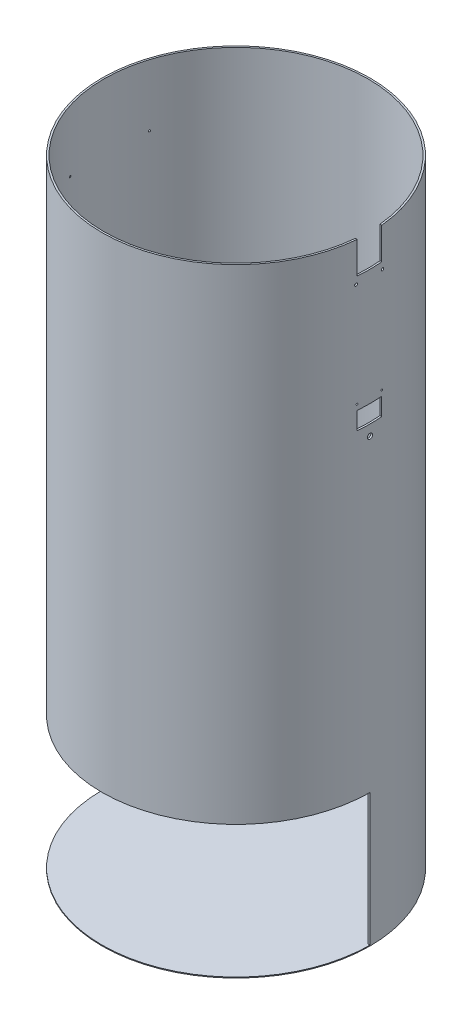
from build123d import *

# Parameters (mm, degrees)
ESQUISSE1_R             = 152
ESQUISSE1_R_2           = 150
BOSS_EXTRU_1_DEPTH      = 700
ESQUISSE2_R             = 152
BOSS_EXTRU_2_DEPTH      = 1
ESQUISSE6_W             = 304
ESQUISSE6_H             = 150
ENL_V_MAT_EXTRU_3_DEPTH = 152
ESQUISSE7_R             = 1.5
ENL_V_MAT_EXTRU_4_DEPTH = 240
ESQUISSE8_R             = 3
ESQUISSE8_R_2           = 1
ESQUISSE8_W             = 28
ESQUISSE8_H             = 20
ENL_V_MAT_EXTRU_5_DEPTH = 220
ESQUISSE9_R             = 1
ENL_V_MAT_EXTRU_6_DEPTH = 170
ESQUISSE10_R            = 1
ENL_V_MAT_EXTRU_8_DEPTH = 220


with BuildPart() as part:
    # Esquisse1 → Boss.-Extru.1 (new body)
    with BuildSketch(Plane(origin=(0, 0, 0), x_dir=(1, 0, 0), z_dir=(0, 1, 0))):
        with Locations(Location((0, 0, 0), (0, 0, 270))):
            Circle(ESQUISSE1_R)
        with Locations(Location((0, 0, 0), (0, 0, 270))):
            Circle(ESQUISSE1_R_2, mode=Mode.SUBTRACT)
    extrude(amount=-BOSS_EXTRU_1_DEPTH)

    # Esquisse2 → Boss.-Extru.2 (add)
    with BuildSketch(Plane(origin=(0, -700, 0), x_dir=(-1, 0, 0), z_dir=(0, -1, 0))):
        with Locations(Location((0, 0, 0), (0, 0, 270))):
            Circle(ESQUISSE2_R)
    extrude(amount=BOSS_EXTRU_2_DEPTH)

    # Esquisse6 → Enlèv. mat.-Extru.3 (cut)
    with BuildSketch(Plane.XY):
        with Locations((0, -625)):
            Rectangle(ESQUISSE6_W, ESQUISSE6_H)
    extrude(amount=ENL_V_MAT_EXTRU_3_DEPTH, mode=Mode.SUBTRACT)

    # Esquisse7 → Enlèv. mat.-Extru.4 (cut)
    with BuildSketch(Plane(origin=(0, 0, 0), x_dir=(0, 0, -1), z_dir=(1, 0, 0))):
        with Locations(Location((-15, -44, 0), (0, 0, 180))):
            Circle(ESQUISSE7_R)
        with Locations(Location((15, -44, 0), (0, 0, 180))):
            Circle(ESQUISSE7_R)
        with BuildLine():
            Line((-4, 0), (-14, 0))
            Line((-14, 0), (-14, -36))
            Line((-14, -36), (14, -36))
            Line((14, -36), (14, 0))
            Line((14, 0), (4, 0))
            ThreePointArc((4, 0), (0, -4), (-4, 0))
        make_face()
    extrude(amount=ENL_V_MAT_EXTRU_4_DEPTH, mode=Mode.SUBTRACT)


with BuildPart() as enl_v_mat_extru_4_kept_piece:
    # of the separate pieces the step leaves, the one the design keeps (enl_v_mat_extru_4_pieces_kept)
    add(part.part.solids().sort_by_distance((0, 0, 152))[0])

    # Esquisse8 → Enlèv. mat.-Extru.5 (cut)
    with BuildSketch(Plane(origin=(0, 0, 0), x_dir=(0, 0, -1), z_dir=(1, 0, 0))):
        with Locations(Location((0, -200, 0), (0, 0, 180))):
            Circle(ESQUISSE8_R)
        with Locations(Location((-14, -162, 0), (0, 0, 180))):
            Circle(ESQUISSE8_R_2)
        with Locations(Location((14, -162, 0), (0, 0, 180))):
            Circle(ESQUISSE8_R_2)
        with Locations((0, -178)):
            Rectangle(ESQUISSE8_W, ESQUISSE8_H)
    extrude(amount=ENL_V_MAT_EXTRU_5_DEPTH, mode=Mode.SUBTRACT)

    # Esquisse9 → Enlèv. mat.-Extru.6 (cut)
    with BuildSketch(Plane(origin=(0, 0, 0), x_dir=(0, 0, -1), z_dir=(1, 0, 0))):
        with Locations((0, -200)):
            Circle(ESQUISSE9_R)
    extrude(amount=-ENL_V_MAT_EXTRU_6_DEPTH, mode=Mode.SUBTRACT)

    # Esquisse10 → Enlèv. mat.-Extru.8 (cut)
    with BuildSketch(Plane(origin=(0, 0, 0), x_dir=(0, 0, -1), z_dir=(1, 0, 0))):
        with Locations((-45, -70)):
            Circle(ESQUISSE10_R)
        with Locations((45, -70)):
            Circle(ESQUISSE10_R)
    extrude(amount=-ENL_V_MAT_EXTRU_8_DEPTH, mode=Mode.SUBTRACT)


solid = enl_v_mat_extru_4_kept_piece.part
